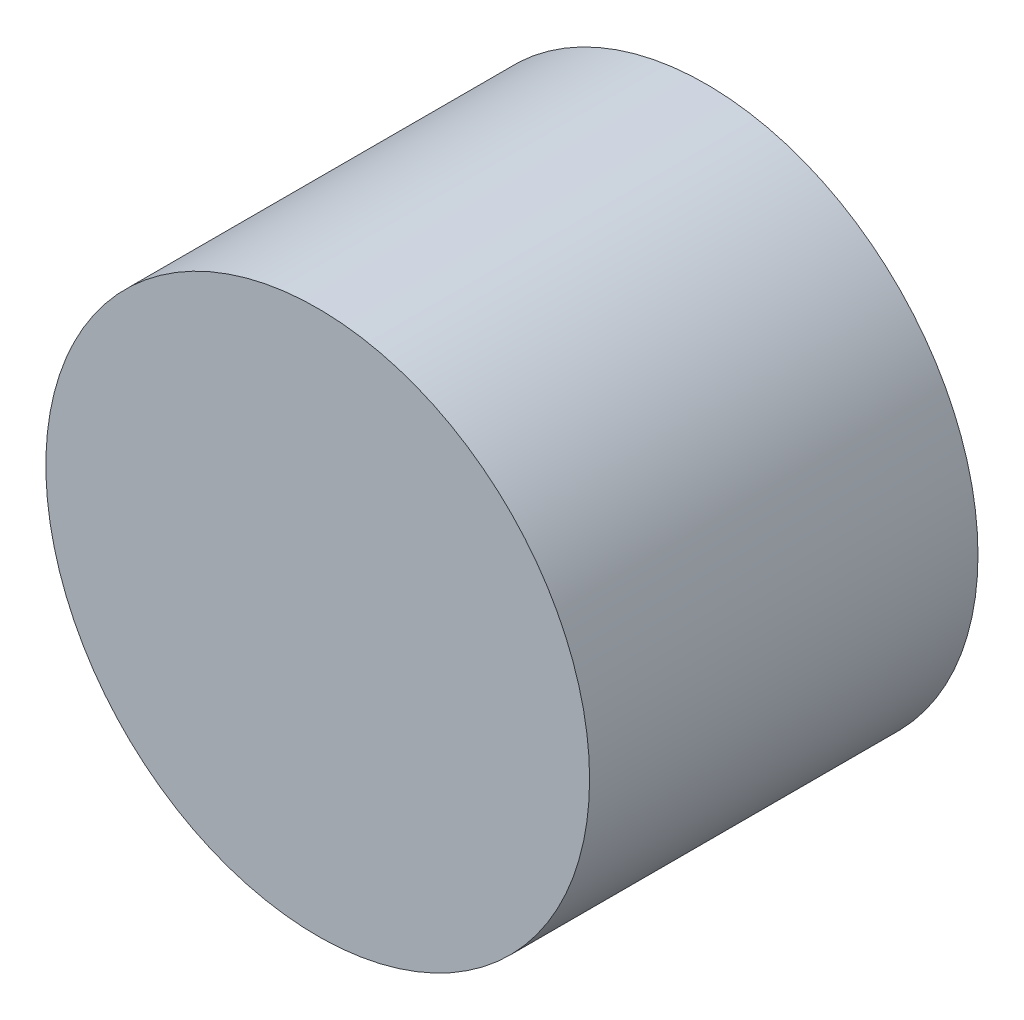
from build123d import *

# Parameters (mm, degrees)
CROQUIS1_R              = 3.5
SALIENTE_EXTRUIR1_DEPTH = 5


with BuildPart() as part:
    # Croquis1 → Saliente-Extruir1 (new body)
    with BuildSketch(Plane.XY):
        with Locations((-4.754102012, 3.97833761)):
            Circle(CROQUIS1_R)
    extrude(amount=SALIENTE_EXTRUIR1_DEPTH)


solid = part.part
